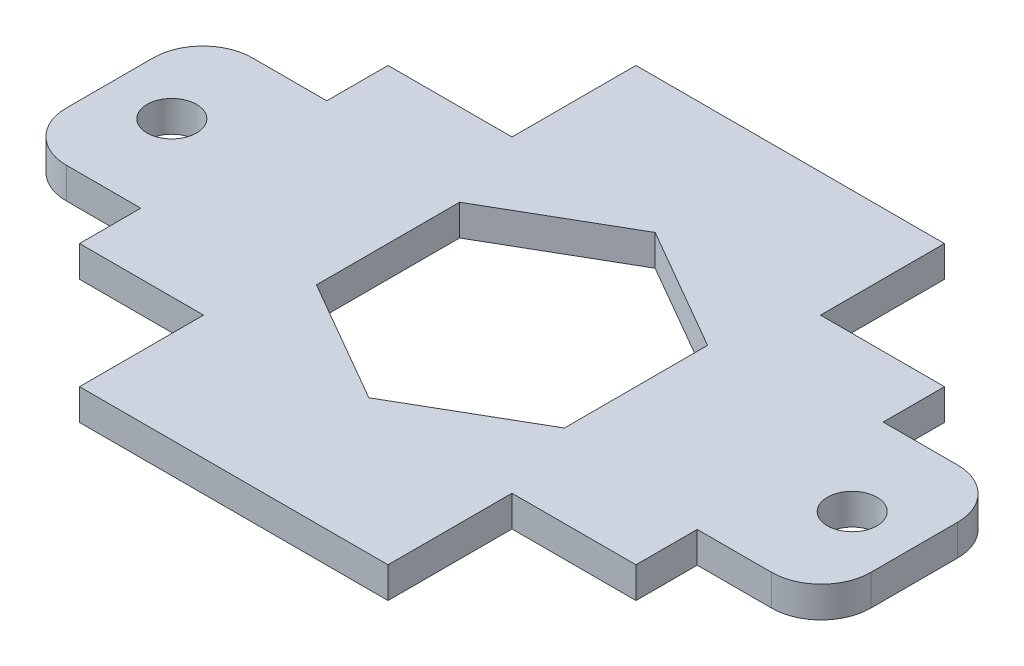
from build123d import *

# Parameters (mm, degrees)
SKETCH1_R           = 2.54
BOSS_EXTRUDE1_DEPTH = 3.175


with BuildPart() as part:
    # Sketch1 → Boss-Extrude1 (new body)
    with BuildSketch(Plane(origin=(0, 0, 0), x_dir=(1, 0, 0), z_dir=(0, 1, 0))):
        with BuildLine():
            Line((-28.4999938, 15.7999938), (-28.4999938, 9.525))
            Line((-28.4999938, 9.525), (-36.1199938, 9.525))
            ThreePointArc((-36.1199938, 9.525), (-39.712096248, 8.037102448), (-41.1999938, 4.445))
            Line((-41.1999938, 4.445), (-41.1999938, -4.445))
            ThreePointArc((-41.1999938, -4.445), (-39.712096248, -8.037102448), (-36.1199938, -9.525))
            Line((-36.1199938, -9.525), (-28.4999938, -9.525))
            Line((-28.4999938, -9.525), (-28.4999938, -15.7999938))
            Line((-28.4999938, -15.7999938), (-15.7999938, -15.7999938))
            Line((-15.7999938, -15.7999938), (-15.7999938, -28.4999938))
            Line((-15.7999938, -28.4999938), (15.7999938, -28.4999938))
            Line((15.7999938, -28.4999938), (15.7999938, -15.7999938))
            Line((15.7999938, -15.7999938), (28.4999938, -15.7999938))
            Line((28.4999938, -15.7999938), (28.4999938, -9.525))
            Line((28.4999938, -9.525), (36.1199938, -9.525))
            ThreePointArc((36.1199938, -9.525), (39.712096248, -8.037102448), (41.1999938, -4.445))
            Line((41.1999938, -4.445), (41.1999938, 4.445))
            ThreePointArc((41.1999938, 4.445), (39.712096248, 8.037102448), (36.1199938, 9.525))
            Line((36.1199938, 9.525), (28.4999938, 9.525))
            Line((28.4999938, 9.525), (28.4999938, 15.7999938))
            Line((28.4999938, 15.7999938), (15.7999938, 15.7999938))
            Line((15.7999938, 15.7999938), (15.7999938, 28.4999938))
            Line((15.7999938, 28.4999938), (-15.7999938, 28.4999938))
            Line((-15.7999938, 28.4999938), (-15.7999938, 15.7999938))
            Line((-15.7999938, 15.7999938), (-28.4999938, 15.7999938))
        make_face()
        with Locations((-34.8499938, 0)):
            Circle(SKETCH1_R, mode=Mode.SUBTRACT)
        with Locations((34.8499938, 0)):
            Circle(SKETCH1_R, mode=Mode.SUBTRACT)
        Polygon((0, 14.664696837), (-12.7, 7.332348419), (-12.7, -7.332348419), (0, -14.664696837), (12.7, -7.332348419), (12.7, 7.332348419), align=None, mode=Mode.SUBTRACT)
    extrude(amount=BOSS_EXTRUDE1_DEPTH)


solid = part.part
